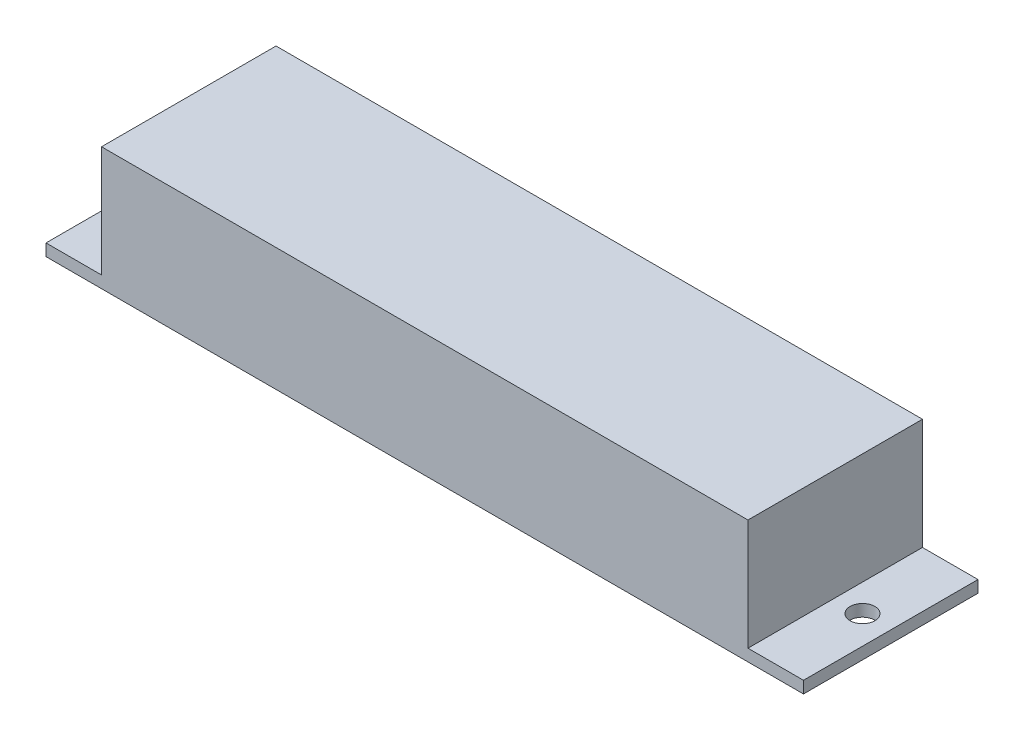
from build123d import *

# Parameters (mm, degrees)
SKETCH1_W           = 97.028
SKETCH1_H           = 22.352
SKETCH1_R           = 1.5875
BOSS_EXTRUDE1_DEPTH = 1.524
SKETCH1_3_W         = 82.804
SKETCH1_3_H         = 22.352
BOSS_EXTRUDE2_DEPTH = 15.748


with BuildPart() as part:
    # Sketch1 → Boss-Extrude1 (new body)
    with BuildSketch(Plane(origin=(0, 0, 0), x_dir=(1, 0, 0), z_dir=(0, 1, 0))):
        with Locations((22.805106227, 0)):
            Rectangle(SKETCH1_W, SKETCH1_H)
        with Locations((-22.089393773, 0)):
            Circle(SKETCH1_R, mode=Mode.SUBTRACT)
        with Locations((67.699606227, 0)):
            Circle(SKETCH1_R, mode=Mode.SUBTRACT)
    extrude(amount=BOSS_EXTRUDE1_DEPTH)

    # Sketch1_3 → Boss-Extrude2 (add)
    with BuildSketch(Plane(origin=(0, 0, 0), x_dir=(1, 0, 0), z_dir=(0, 1, 0))):
        with Locations((22.805106227, 0)):
            Rectangle(SKETCH1_3_W, SKETCH1_3_H)
    extrude(amount=BOSS_EXTRUDE2_DEPTH)


solid = part.part
